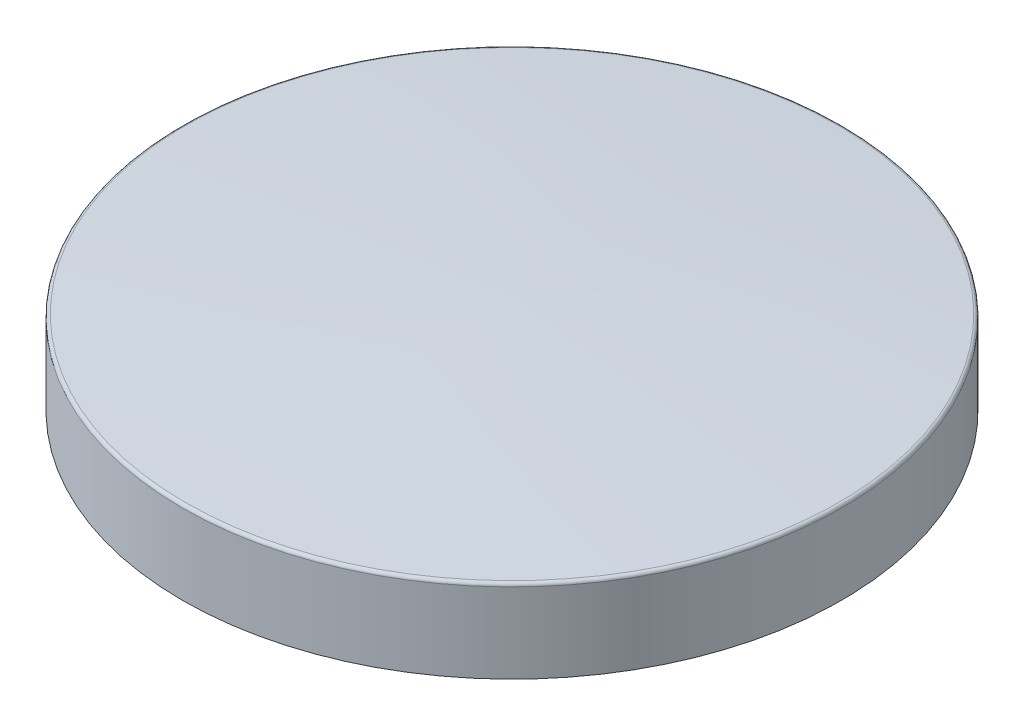
from build123d import *

# Parameters (mm, degrees)
FILLET1_R           = 0.1
CUT_EXTRUDE30_DEPTH = 2.5
CUT_EXTRUDE32_DEPTH = 2.5


with BuildPart() as part:
    # Sketch2 → Revolve1 (revolve)
    with BuildSketch(Plane.XY, mode=Mode.PRIVATE) as revolve1_sk:
        with BuildLine():
            Line((0, 0), (0, -2.994068148))
            Line((0, -2.994068148), (10, -2.994068148))
            Line((10, -2.994068148), (10, -0.476375913))
            ThreePointArc((10, -0.476375913), (5.003053336, -0.174092863), (0, 0))
        make_face()
    revolve(revolve1_sk.sketch.rotate(Axis((0, 0, 0), (0, -1, 0)), 90), axis=Axis((0, 0, 0), (0, -1, 0)))  # turned: the seam where the file's is

    # Fillet1
    fillet1_edges = [part.edges().sort_by_distance(p)[0] for p in [
        (0, -0.476375913, -10),
    ]]
    fillet(fillet1_edges, radius=FILLET1_R)

    # Sketch14 → Cut-Extrude30 (cut)
    with BuildSketch(Plane(origin=(0, -2.994068148, 0), x_dir=(-1, 0, 0), z_dir=(0, -1, 0))):
        Polygon((5.240635003, 5.742951642), (4.130859362, 5.742951642), (4.130859362, 1.742951642), (4.84880808, 1.742951642), (4.84880808, 5.076284975), (5.6693209, 5.076284975), align=None)
        with BuildLine():
            Line((0.438551669, 4.768592667), (1.156500387, 4.768592667))
            add(Edge.make_bspline(
                [(1.156500387, 4.768592667), (1.151431396, 4.804480362), (1.141493975, 4.874835812), (1.117715056, 4.976692975), (1.089272902, 5.073311466), (1.053764326, 5.164385313), (1.012118543, 5.250076748), (0.964759045, 5.330679823), (0.911173856, 5.405848574), (0.870100242, 5.451130528), (0.849609362, 5.473720872)],
                knots=[0, 0, 0, 0, 1.111473889, 2.178970933, 3.205615836, 4.199322666, 5.174200091, 6.12565194, 7.064921805, 8, 8, 8, 8], degree=3))
            add(Edge.make_bspline(
                [(0.849609362, 5.473720872), (0.820053982, 5.503527195), (0.761803436, 5.562272323), (0.664459941, 5.637518344), (0.562425981, 5.702638658), (0.453655221, 5.754266514), (0.339840215, 5.796053283), (0.220075866, 5.824121549), (0.094851577, 5.842745092), (0.009401752, 5.844579576), (-0.034204741, 5.845515744)],
                knots=[0, 0, 0, 0, 1.01925491, 2.00884431, 2.983262333, 3.955970413, 4.92937149, 5.924503185, 6.940838805, 8, 8, 8, 8], degree=3))
            add(Edge.make_bspline(
                [(-0.034204741, 5.845515744), (-0.072973157, 5.844600498), (-0.149184051, 5.842801308), (-0.26119489, 5.828358388), (-0.367987851, 5.803027115), (-0.470691766, 5.769907043), (-0.567796197, 5.724841651), (-0.661444331, 5.672530322), (-0.749019638, 5.608368303), (-0.830727026, 5.535871679), (-0.905790845, 5.457459484), (-0.970796441, 5.373643295), (-1.026682919, 5.286662037), (-1.072725984, 5.195793059), (-1.108126845, 5.100882602), (-1.132696092, 5.002478949), (-1.148777261, 4.900799235), (-1.150379365, 4.831688903), (-1.15119192, 4.796637539)],
                knots=[0, 0, 0, 0, 1.091422571, 2.145516843, 3.172569842, 4.178562979, 5.178154469, 6.181868002, 7.194278174, 8.227918432, 9.254613415, 10.245994977, 11.209837596, 12.161663635, 13.10878368, 14.055455738, 15.013766427, 16, 16, 16, 16], degree=3))
            add(Edge.make_bspline(
                [(-1.15119192, 4.796637539), (-1.149524509, 4.753229343), (-1.146241888, 4.667771951), (-1.119305607, 4.542698708), (-1.077143004, 4.423106368), (-1.016235022, 4.310668207), (-0.940084532, 4.205690219), (-0.846650431, 4.111682132), (-0.738593964, 4.027170029), (-0.657474536, 3.981753214), (-0.61593551, 3.958496513)],
                knots=[0, 0, 0, 0, 0.992805628, 1.954529043, 2.915727527, 3.886831945, 4.871318353, 5.87440735, 6.911542536, 8, 8, 8, 8], degree=3))
            add(Edge.make_bspline(
                [(-0.61593551, 3.958496513), (-0.64444726, 3.949135506), (-0.70047157, 3.930741545), (-0.78010339, 3.894514848), (-0.855824152, 3.854925073), (-0.926329971, 3.80893219), (-0.992322112, 3.758395948), (-1.053398281, 3.702884346), (-1.109923392, 3.642518423), (-1.160974697, 3.576966191), (-1.206284724, 3.507276029), (-1.246938999, 3.43505774), (-1.280399733, 3.359216119), (-1.308745141, 3.28061733), (-1.330325721, 3.198554967), (-1.345520377, 3.113347016), (-1.354303262, 3.025187842), (-1.355642802, 2.965460054), (-1.356320125, 2.935259334)],
                knots=[0, 0, 0, 0, 1.059543567, 2.081955587, 3.086750234, 4.076226789, 5.052108497, 6.020845489, 6.989030705, 7.970690546, 8.952259656, 9.923888338, 10.895517021, 11.877585046, 12.873342345, 13.889638361, 14.932918083, 16, 16, 16, 16], degree=3))
            add(Edge.make_bspline(
                [(-1.356320125, 2.935259334), (-1.354947099, 2.890876537), (-1.35223977, 2.8033627), (-1.335027839, 2.674463774), (-1.302982324, 2.551570101), (-1.260824675, 2.433267602), (-1.204590946, 2.321083521), (-1.138413301, 2.212443385), (-1.057067679, 2.111114805), (-0.966665987, 2.014418915), (-0.866269638, 1.926507342), (-0.757423663, 1.850291964), (-0.642521492, 1.784885609), (-0.520836171, 1.731786866), (-0.392409975, 1.690894762), (-0.257529157, 1.661336064), (-0.115626984, 1.643251563), (-0.018767648, 1.641355746), (0.030699105, 1.640387539)],
                knots=[0, 0, 0, 0, 1.005138573, 1.981928558, 2.936866704, 3.876260664, 4.820238198, 5.773547, 6.751179199, 7.756627054, 8.768222608, 9.766606018, 10.760583154, 11.757261445, 12.767156078, 13.807575856, 14.880313354, 16, 16, 16, 16], degree=3))
            add(Edge.make_bspline(
                [(0.030699105, 1.640387539), (0.077493856, 1.64140835), (0.1689948, 1.64340441), (0.30283408, 1.660681326), (0.430035646, 1.688550393), (0.55092412, 1.727834154), (0.665031794, 1.778778478), (0.77339344, 1.839441738), (0.873846725, 1.913322849), (0.967510898, 1.997086678), (1.052308203, 2.091064938), (1.128097025, 2.193080669), (1.193206207, 2.303521795), (1.247902761, 2.421916467), (1.291759085, 2.548472382), (1.326352825, 2.682932185), (1.350517118, 2.825558568), (1.357876404, 2.923688553), (1.361628592, 2.973720872)],
                knots=[0, 0, 0, 0, 1.066544725, 2.085487077, 3.070979577, 4.031932826, 4.977951092, 5.916076795, 6.857635327, 7.814973522, 8.776389752, 9.738577119, 10.707772778, 11.69409279, 12.707140348, 13.757286496, 14.856535458, 16, 16, 16, 16], degree=3))
            Line((1.361628592, 2.973720872), (0.643679875, 2.973720872))
            add(Edge.make_bspline(
                [(0.643679875, 2.973720872), (0.639130308, 2.948563965), (0.630268835, 2.899564292), (0.612985075, 2.828623657), (0.590461925, 2.763141069), (0.564419559, 2.702534521), (0.536289883, 2.646008271), (0.502302508, 2.595649971), (0.464947849, 2.550092188), (0.411044805, 2.495932594), (0.333986691, 2.440285872), (0.229932708, 2.391926223), (0.114182505, 2.363581528), (0.03326157, 2.360123562), (-0.008563715, 2.358336257)],
                knots=[0, 0, 0, 0, 0.928156231, 1.807827665, 2.648129825, 3.438902246, 4.202261636, 4.936546065, 5.639352463, 6.338805438, 7.70633318, 9.064371875, 10.482673459, 12, 12, 12, 12], degree=3))
            add(Edge.make_bspline(
                [(-0.008563715, 2.358336257), (-0.03075769, 2.358716847), (-0.074230721, 2.359462337), (-0.13808613, 2.367725099), (-0.198917399, 2.381333873), (-0.256837828, 2.399827693), (-0.312216142, 2.423010853), (-0.363994283, 2.45290415), (-0.41322762, 2.487659375), (-0.459380941, 2.526733475), (-0.50202756, 2.569310256), (-0.537512055, 2.616456807), (-0.569942317, 2.664366131), (-0.593927971, 2.716172622), (-0.614944572, 2.769088539), (-0.627807806, 2.825034563), (-0.637520471, 2.882837098), (-0.638084932, 2.922394615), (-0.638371408, 2.942470872)],
                knots=[0, 0, 0, 0, 1.110435564, 2.175094844, 3.216326037, 4.226890168, 5.215276772, 6.21526065, 7.213097102, 8.228249917, 9.239874822, 10.221364777, 11.178138315, 12.128914389, 13.072518965, 14.022636769, 14.996447288, 16, 16, 16, 16], degree=3))
            add(Edge.make_bspline(
                [(-0.638371408, 2.942470872), (-0.637610868, 2.964427681), (-0.636096809, 3.008138655), (-0.623726784, 3.07192563), (-0.604191901, 3.133283559), (-0.577055562, 3.191940721), (-0.540818005, 3.247680916), (-0.498058092, 3.301622462), (-0.44540705, 3.350957797), (-0.387641805, 3.399724281), (-0.320656814, 3.442233947), (-0.24771434, 3.481464123), (-0.166897342, 3.512679231), (-0.080178634, 3.540560104), (0.014082149, 3.560923861), (0.115299682, 3.575709934), (0.223310686, 3.586715873), (0.297764075, 3.588294856), (0.335987567, 3.589105488)],
                knots=[0, 0, 0, 0, 0.809814727, 1.612155564, 2.388397, 3.182215007, 3.988903953, 4.837162975, 5.715530372, 6.646997145, 7.623086902, 8.637258368, 9.698941581, 10.815059213, 11.996518529, 13.252603015, 14.589518788, 16, 16, 16, 16], degree=3))
            Line((0.335987567, 3.589105488), (0.335987567, 4.255772154))
            add(Edge.make_bspline(
                [(0.335987567, 4.255772154), (0.288397046, 4.259825115), (0.199364607, 4.267407403), (0.075782807, 4.285138846), (-0.028257138, 4.308839838), (-0.11525583, 4.337433803), (-0.18749397, 4.374155903), (-0.25060081, 4.41469548), (-0.304951406, 4.461776274), (-0.35088495, 4.513994342), (-0.387630356, 4.570071651), (-0.413636614, 4.629136592), (-0.430809788, 4.689361624), (-0.432436944, 4.730553731), (-0.433243202, 4.750964462)],
                knots=[0, 0, 0, 0, 1.70044513, 3.18119609, 4.440695891, 5.496282586, 6.431922213, 7.318171381, 8.16090191, 8.983045123, 9.787564368, 10.536848927, 11.275007137, 12, 12, 12, 12], degree=3))
            add(Edge.make_bspline(
                [(-0.433243202, 4.750964462), (-0.431852177, 4.777006339), (-0.429137189, 4.82783457), (-0.408051124, 4.900580475), (-0.371448103, 4.96542742), (-0.32236988, 5.022238949), (-0.262566359, 5.069692196), (-0.192466148, 5.104142444), (-0.113590427, 5.124383503), (-0.058097107, 5.126481818), (-0.029397049, 5.127567026)],
                knots=[0, 0, 0, 0, 1.009664648, 1.970651636, 2.907870547, 3.878035693, 4.867062054, 5.849714035, 6.887914197, 8, 8, 8, 8], degree=3))
            add(Edge.make_bspline(
                [(-0.029397049, 5.127567026), (-0.003383672, 5.126286595), (0.048234834, 5.123745828), (0.12371654, 5.104782212), (0.195399012, 5.072859324), (0.26179791, 5.028839543), (0.321954752, 4.975973653), (0.371326162, 4.913364979), (0.412390961, 4.844764516), (0.429797248, 4.794082822), (0.438551669, 4.768592667)],
                knots=[0, 0, 0, 0, 0.98818071, 1.960853194, 2.938124878, 3.957524365, 4.978590984, 5.968022688, 6.978025184, 8, 8, 8, 8], degree=3))
        make_face()
        with BuildLine():
            Line((-3.996544484, 5.742951642), (-5.817858587, 5.742951642))
            Line((-5.817858587, 5.742951642), (-5.817858587, 5.076284975))
            Line((-5.817858587, 5.076284975), (-4.565454741, 5.076284975))
            Line((-4.565454741, 5.076284975), (-4.409204741, 4.319874719))
            add(Edge.make_bspline(
                [(-4.409204741, 4.319874719), (-4.43049604, 4.325804614), (-4.472486857, 4.337499587), (-4.535746074, 4.349228164), (-4.597053071, 4.356830256), (-4.637282348, 4.357844273), (-4.656800895, 4.358336257)],
                knots=[0, 0, 0, 0, 1.05461699, 2.079921384, 3.068411212, 4, 4, 4, 4], degree=3))
            add(Edge.make_bspline(
                [(-4.656800895, 4.358336257), (-4.699333852, 4.357361639), (-4.783175681, 4.355440452), (-4.905825638, 4.337202122), (-5.023270217, 4.308477304), (-5.135150024, 4.267509787), (-5.241355769, 4.214189506), (-5.342016194, 4.149686913), (-5.437254842, 4.073888718), (-5.525379875, 3.986747464), (-5.606352836, 3.891064395), (-5.676754207, 3.787573031), (-5.736881371, 3.677749058), (-5.784704439, 3.560909814), (-5.822450481, 3.437789127), (-5.849726614, 3.308308098), (-5.865856354, 3.172313273), (-5.86803135, 3.079533726), (-5.869140638, 3.032214462)],
                knots=[0, 0, 0, 0, 1.01440847, 1.999622559, 2.951875003, 3.895578053, 4.836219714, 5.782137149, 6.743708247, 7.735272588, 8.734977101, 9.730283169, 10.717124674, 11.717316708, 12.737475749, 13.78628267, 14.87096371, 16, 16, 16, 16], degree=3))
            add(Edge.make_bspline(
                [(-5.869140638, 3.032214462), (-5.867785071, 2.984358015), (-5.865110139, 2.889923255), (-5.847658663, 2.751070755), (-5.816856493, 2.618081406), (-5.774546632, 2.490599199), (-5.718806098, 2.369561098), (-5.651770477, 2.253713238), (-5.572306378, 2.143915521), (-5.481193615, 2.041293508), (-5.38214209, 1.947495017), (-5.276675598, 1.864980305), (-5.165535073, 1.795544844), (-5.048717832, 1.739429252), (-4.926894094, 1.695031594), (-4.800026884, 1.662712219), (-4.667499644, 1.644178853), (-4.577530867, 1.641665198), (-4.531800895, 1.640387539)],
                knots=[0, 0, 0, 0, 1.06808661, 2.107647099, 3.116961351, 4.110378221, 5.100014249, 6.085620622, 7.093190682, 8.119403071, 9.144090782, 10.133780668, 11.103064255, 12.062861538, 13.020824475, 13.992378307, 14.979551724, 16, 16, 16, 16], degree=3))
            add(Edge.make_bspline(
                [(-4.531800895, 1.640387539), (-4.490905942, 1.641432743), (-4.410252537, 1.643494105), (-4.291453613, 1.656164319), (-4.176918258, 1.678565377), (-4.067254529, 1.710985507), (-3.961308581, 1.750887287), (-3.860305179, 1.800792003), (-3.763689292, 1.859749402), (-3.671735273, 1.926683511), (-3.585937243, 2.002082188), (-3.507629893, 2.084619032), (-3.436339141, 2.173253705), (-3.373590495, 2.269079689), (-3.319580654, 2.371955408), (-3.271683626, 2.480668447), (-3.232479429, 2.596354117), (-3.212584428, 2.676553851), (-3.202473972, 2.717310616)],
                knots=[0, 0, 0, 0, 1.054957082, 2.080596141, 3.077793124, 4.061112343, 5.027190972, 5.994718051, 6.962465889, 7.943658696, 8.924948258, 9.904494768, 10.875059, 11.855380583, 12.854004648, 13.869083016, 14.917087635, 16, 16, 16, 16], degree=3))
            Line((-3.202473972, 2.717310616), (-4.022986792, 2.717310616))
            add(Edge.make_bspline(
                [(-4.022986792, 2.717310616), (-4.037985786, 2.689067837), (-4.06713462, 2.63418122), (-4.122582145, 2.561310988), (-4.18465213, 2.499170385), (-4.252784668, 2.447152284), (-4.327421218, 2.408181208), (-4.405520479, 2.378627346), (-4.48806358, 2.361549264), (-4.544279077, 2.359414335), (-4.572666279, 2.358336257)],
                knots=[0, 0, 0, 0, 1.104910296, 2.147267069, 3.153527244, 4.136738762, 5.099945312, 6.05603338, 7.018353, 8, 8, 8, 8], degree=3))
            add(Edge.make_bspline(
                [(-4.572666279, 2.358336257), (-4.592451778, 2.359080679), (-4.631380081, 2.360545342), (-4.68873478, 2.368293777), (-4.74348236, 2.382969137), (-4.796029855, 2.403291099), (-4.846518423, 2.428634882), (-4.894224292, 2.460629756), (-4.939977458, 2.497457042), (-4.983081373, 2.539716477), (-5.022121095, 2.586825918), (-5.056354661, 2.637448223), (-5.08696419, 2.690458555), (-5.109637137, 2.747956785), (-5.128204362, 2.808225997), (-5.141878018, 2.871720818), (-5.15004957, 2.938515407), (-5.150806037, 2.9841142), (-5.15119192, 3.007374719)],
                knots=[0, 0, 0, 0, 0.978869489, 1.925942215, 2.855067702, 3.774946051, 4.70828698, 5.642468714, 6.60995405, 7.609372294, 8.622401667, 9.629904756, 10.629323, 11.642352373, 12.678539694, 13.745912462, 14.850161547, 16, 16, 16, 16], degree=3))
            add(Edge.make_bspline(
                [(-5.15119192, 3.007374719), (-5.150744058, 3.030095308), (-5.149872283, 3.074321487), (-5.142660787, 3.139261359), (-5.12975956, 3.200877545), (-5.112181528, 3.25964198), (-5.089679548, 3.315197816), (-5.062180624, 3.367875749), (-5.029567278, 3.417409511), (-4.991664416, 3.462790644), (-4.951245194, 3.504415509), (-4.907821962, 3.540820285), (-4.861785939, 3.571033721), (-4.81456764, 3.59741093), (-4.764282278, 3.616607688), (-4.71206057, 3.629827787), (-4.657957434, 3.639528163), (-4.62105486, 3.640098096), (-4.602313715, 3.640387539)],
                knots=[0, 0, 0, 0, 1.166249705, 2.270133367, 3.348514167, 4.393962215, 5.415026464, 6.420877785, 7.440098956, 8.453121383, 9.451844239, 10.415694839, 11.355045125, 12.27538808, 13.187007209, 14.108269027, 15.039275622, 16, 16, 16, 16], degree=3))
            add(Edge.make_bspline(
                [(-4.602313715, 3.640387539), (-4.581956477, 3.639615095), (-4.541156203, 3.638066951), (-4.480537209, 3.625470119), (-4.420649111, 3.60508372), (-4.361158871, 3.576957451), (-4.302657031, 3.540149041), (-4.2435997, 3.496976995), (-4.185963653, 3.444304455), (-4.149317051, 3.405073828), (-4.130358587, 3.384778565)],
                knots=[0, 0, 0, 0, 0.88288272, 1.769486374, 2.674910571, 3.623812639, 4.617874466, 5.670434592, 6.794841017, 8, 8, 8, 8], degree=3))
            Line((-4.130358587, 3.384778565), (-3.52619192, 3.52340036))
            Line((-3.52619192, 3.52340036), (-3.996544484, 5.742951642))
        make_face()
        with BuildLine():
            Line((5.207782439, -3.103202205), (5.925731157, -3.103202205))
            add(Edge.make_bspline(
                [(5.925731157, -3.103202205), (5.922630446, -3.048893182), (5.916571844, -2.942776613), (5.892472257, -2.788638899), (5.860179637, -2.642995709), (5.817080849, -2.506356519), (5.762924401, -2.378770979), (5.69910388, -2.259804142), (5.623988815, -2.150082372), (5.539177901, -2.05013481), (5.446110996, -1.96047093), (5.346720259, -1.8809693), (5.239485376, -1.815366556), (5.126365614, -1.761381572), (5.007380237, -1.718250078), (4.881403455, -1.689413184), (4.749526044, -1.669884557), (4.659245277, -1.668175723), (4.613231157, -1.667304769)],
                knots=[0, 0, 0, 0, 1.199038563, 2.342849363, 3.436047546, 4.486744587, 5.497670872, 6.488682221, 7.459191391, 8.424610317, 9.374430501, 10.305433194, 11.225809216, 12.140057399, 13.06607119, 14.010487599, 14.985989317, 16, 16, 16, 16], degree=3))
            add(Edge.make_bspline(
                [(4.613231157, -1.667304769), (4.556749477, -1.669067146), (4.446484002, -1.672507719), (4.286259522, -1.701856953), (4.136627375, -1.750948082), (3.997696331, -1.819541335), (3.870649134, -1.906681874), (3.755506852, -2.010582704), (3.655751571, -2.13342372), (3.570750813, -2.270093708), (3.500125343, -2.414807991), (3.450633955, -2.56444856), (3.418103798, -2.715044562), (3.414634256, -2.816448288), (3.412910644, -2.866823999)],
                knots=[0, 0, 0, 0, 1.075374347, 2.099382735, 3.09057751, 4.06680945, 5.040638231, 6.016817125, 7.011024321, 8.044445721, 9.0776792, 10.070479129, 11.0414456, 12, 12, 12, 12], degree=3))
            add(Edge.make_bspline(
                [(3.412910644, -2.866823999), (3.413581727, -2.89729479), (3.414932453, -2.958624965), (3.424324225, -3.051432573), (3.438413739, -3.145967972), (3.459657293, -3.242150107), (3.486149746, -3.34000594), (3.518288921, -3.439828318), (3.556820318, -3.541051287), (3.601100925, -3.644814093), (3.653927802, -3.751453613), (3.715437357, -3.862568415), (3.787262193, -3.978059932), (3.868534757, -4.098580267), (3.95964977, -4.22393934), (4.061052026, -4.35375953), (4.171573609, -4.488498283), (4.250013885, -4.578563578), (4.29031449, -4.62483682)],
                knots=[0, 0, 0, 0, 0.728284026, 1.46585585, 2.227944881, 3.01186502, 3.81876927, 4.650621989, 5.517437689, 6.406905708, 7.346299482, 8.360816762, 9.441613733, 10.596154504, 11.834900912, 13.145207542, 14.533280747, 16, 16, 16, 16], degree=3))
            Line((4.29031449, -4.62483682), (4.707782439, -5.103202205))
            Line((4.707782439, -5.103202205), (3.361628592, -5.103202205))
            Line((3.361628592, -5.103202205), (3.361628592, -5.769868871))
            Line((3.361628592, -5.769868871), (6.028295259, -5.769868871))
            Line((6.028295259, -5.769868871), (6.028295259, -5.40608682))
            Line((6.028295259, -5.40608682), (4.844000387, -4.145670153))
            add(Edge.make_bspline(
                [(4.844000387, -4.145670153), (4.809712007, -4.108903408), (4.743305584, -4.037697125), (4.648816087, -3.933123123), (4.563311439, -3.833884892), (4.488564648, -3.738925743), (4.420653099, -3.651325767), (4.362604963, -3.568444589), (4.313889145, -3.491031486), (4.261001214, -3.397684804), (4.210775066, -3.286352275), (4.164689535, -3.158092636), (4.136597214, -3.035505961), (4.132719586, -2.955625848), (4.130859362, -2.917304769)],
                knots=[0, 0, 0, 0, 1.246127091, 2.413378631, 3.493388633, 4.492180848, 5.408488754, 6.240484944, 6.999099869, 7.674939598, 8.898438119, 10.020720584, 11.050475521, 12, 12, 12, 12], degree=3))
            add(Edge.make_bspline(
                [(4.130859362, -2.917304769), (4.132250206, -2.880232081), (4.134945191, -2.808397806), (4.164560886, -2.706213931), (4.210442548, -2.613696864), (4.27509629, -2.533611118), (4.353412221, -2.467799351), (4.443913635, -2.418850407), (4.545862681, -2.39060709), (4.617330904, -2.387072036), (4.654096541, -2.385253487)],
                knots=[0, 0, 0, 0, 1.062038974, 2.057870785, 3.028805853, 4.01125022, 4.991535629, 5.949134679, 6.94496649, 8, 8, 8, 8], degree=3))
            add(Edge.make_bspline(
                [(4.654096541, -2.385253487), (4.673090138, -2.385925281), (4.710482083, -2.387247815), (4.765445319, -2.396051569), (4.817746788, -2.411567267), (4.867968632, -2.432356119), (4.915574872, -2.459911891), (4.96044543, -2.49387877), (5.003053073, -2.533393581), (5.043202386, -2.578332766), (5.079743503, -2.628484909), (5.112199188, -2.683391974), (5.139034637, -2.743019877), (5.162661542, -2.80658144), (5.180883742, -2.874759366), (5.194151763, -2.947145617), (5.204238554, -3.02362243), (5.206579654, -3.076193047), (5.207782439, -3.103202205)],
                knots=[0, 0, 0, 0, 0.903469896, 1.778625579, 2.63899355, 3.493148037, 4.358286772, 5.247621495, 6.164656832, 7.118446693, 8.109501108, 9.111810964, 10.146451449, 11.215617525, 12.33435995, 13.498009769, 14.714554818, 16, 16, 16, 16], degree=3))
        make_face()
        Polygon((-0.248948331, -1.667304769), (-0.997345766, -1.667304769), (-0.997345766, -4.282689384), (-1.356320125, -4.282689384), (-1.356320125, -4.949356051), (-0.997345766, -4.949356051), (-0.997345766, -5.769868871), (-0.279397049, -5.769868871), (-0.279397049, -4.949356051), (1.412910644, -4.949356051), (1.412910644, -4.22259323), align=None)
        Polygon((-0.279397049, -4.282689384), (-0.279397049, -2.921311179), (0.606019618, -4.282689384), align=None, mode=Mode.SUBTRACT)
        with BuildLine():
            Line((-3.561448331, -1.769868871), (-4.397986792, -1.769868871))
            add(Edge.make_bspline(
                [(-4.397986792, -1.769868871), (-4.45328173, -1.770065137), (-4.559629471, -1.77044261), (-4.712977104, -1.776398141), (-4.853847995, -1.784685751), (-4.982450714, -1.797332865), (-5.098730243, -1.814101408), (-5.202803122, -1.833868746), (-5.294666309, -1.856397866), (-5.375094542, -1.884470926), (-5.447677046, -1.916136913), (-5.51533403, -1.952521713), (-5.579558108, -1.993220168), (-5.639920012, -2.039303167), (-5.696944302, -2.089941687), (-5.750738555, -2.145186701), (-5.800542611, -2.205506663), (-5.84604808, -2.270520429), (-5.887522652, -2.33891342), (-5.924177475, -2.410779539), (-5.953985238, -2.486168766), (-5.980323592, -2.563991562), (-5.999294255, -2.645360421), (-6.012488073, -2.729483201), (-6.022148071, -2.816656025), (-6.022703475, -2.875877372), (-6.022986792, -2.90608682)],
                knots=[0, 0, 0, 0, 1.749336639, 3.364467119, 4.854658419, 6.213483162, 7.451590619, 8.570285859, 9.5643256, 10.440900261, 11.26203566, 12.067320669, 12.869050712, 13.665104639, 14.467235401, 15.27997916, 16.102287765, 16.939272006, 17.78853747, 18.631303466, 19.488103222, 20.351255419, 21.228522269, 22.127379805, 23.044756219, 24, 24, 24, 24], degree=3))
            add(Edge.make_bspline(
                [(-6.022986792, -2.90608682), (-6.022250835, -2.937618544), (-6.020807758, -2.999446508), (-6.01303456, -3.090266745), (-5.998827595, -3.177157194), (-5.97730908, -3.259863453), (-5.952576342, -3.339414895), (-5.919688145, -3.414343749), (-5.882570564, -3.485739744), (-5.838487098, -3.552592958), (-5.790107647, -3.616388335), (-5.733843363, -3.674681636), (-5.673339308, -3.730605906), (-5.605194328, -3.780658239), (-5.532412318, -3.828222992), (-5.453547174, -3.871329325), (-5.369113599, -3.911060832), (-5.309752614, -3.933217865), (-5.279397049, -3.944548358)],
                knots=[0, 0, 0, 0, 1.099860209, 2.156625411, 3.176576793, 4.16617041, 5.135385252, 6.078461593, 7.016046972, 7.938469504, 8.868247731, 9.803980173, 10.76021508, 11.73834243, 12.748633912, 13.790971185, 14.870363756, 16, 16, 16, 16], degree=3))
            Line((-5.279397049, -3.944548358), (-6.202473972, -5.769868871))
            Line((-6.202473972, -5.769868871), (-5.404397049, -5.769868871))
            Line((-5.404397049, -5.769868871), (-4.522986792, -4.026279128))
            Line((-4.522986792, -4.026279128), (-4.279397049, -4.026279128))
            Line((-4.279397049, -4.026279128), (-4.279397049, -5.769868871))
            Line((-4.279397049, -5.769868871), (-3.561448331, -5.769868871))
            Line((-3.561448331, -5.769868871), (-3.561448331, -1.769868871))
        make_face()
        with BuildLine():
            Line((-4.279397049, -3.30833041), (-4.559044484, -3.30833041))
            add(Edge.make_bspline(
                [(-4.559044484, -3.30833041), (-4.593233708, -3.307945348), (-4.658698725, -3.307208037), (-4.752846017, -3.303788083), (-4.838354212, -3.295547683), (-4.91559051, -3.285136246), (-4.984943556, -3.273114739), (-5.045794747, -3.255887189), (-5.099081707, -3.237427433), (-5.144172982, -3.214486745), (-5.182697932, -3.188398207), (-5.21596176, -3.158760979), (-5.243475715, -3.124459662), (-5.266121104, -3.086426417), (-5.283736754, -3.04432485), (-5.29659483, -2.99861714), (-5.303780592, -2.948782618), (-5.304607339, -2.914390012), (-5.305038074, -2.896471435)],
                knots=[0, 0, 0, 0, 1.688639943, 3.233382647, 4.650958383, 5.928841754, 7.082724185, 8.122798841, 9.049171256, 9.863274652, 10.613301712, 11.341792392, 12.054588806, 12.776240173, 13.521029143, 14.301969904, 15.115324896, 16, 16, 16, 16], degree=3))
            add(Edge.make_bspline(
                [(-5.305038074, -2.896471435), (-5.304223729, -2.875272451), (-5.302624099, -2.833630975), (-5.286750799, -2.773681851), (-5.261483934, -2.718194835), (-5.226849983, -2.667420631), (-5.183233024, -2.622908459), (-5.133179123, -2.583670625), (-5.075607995, -2.552644282), (-5.022301462, -2.532179636), (-4.973804978, -2.519935427), (-4.93003843, -2.510811151), (-4.879356505, -2.504344515), (-4.82172094, -2.497485496), (-4.75727865, -2.49303777), (-4.685678385, -2.489791816), (-4.607125782, -2.488463737), (-4.552367157, -2.488039173), (-4.523788074, -2.487817589)],
                knots=[0, 0, 0, 0, 1.020303359, 2.004196876, 2.966617323, 3.9489082, 4.950758222, 5.960522915, 7.003732012, 8.091992268, 8.70421221, 9.413913587, 10.24622431, 11.166358409, 12.212345909, 13.359657661, 14.621978493, 16, 16, 16, 16], degree=3))
            Line((-4.523788074, -2.487817589), (-4.279397049, -2.487817589))
            Line((-4.279397049, -2.487817589), (-4.279397049, -3.30833041))
        make_face(mode=Mode.SUBTRACT)
    extrude(amount=-CUT_EXTRUDE30_DEPTH, mode=Mode.SUBTRACT)

    # Sketch15 → Cut-Extrude32 (cut)
    with BuildSketch(Plane(origin=(0, -2.994068148, 0), x_dir=(-1, 0, 0), z_dir=(0, -1, 0))):
        Polygon((4.84880808, 1.01972759), (4.04880808, 1.01972759), (4.04880808, 0.293381337), (0.34880808, 0.293381337), (0.34880808, 1.01972759), (-0.45119192, 1.01972759), (-0.45119192, 0.293381337), (-4.15119192, 0.293381337), (-4.15119192, 1.01972759), (-4.95119192, 1.01972759), (-4.95119192, -1.01972759), (-4.15119192, -1.01972759), (-4.15119192, -0.293381337), (-0.45119192, -0.293381337), (-0.45119192, -1.01972759), (0.34880808, -1.01972759), (0.34880808, -0.293381337), (4.04880808, -0.293381337), (4.04880808, -1.01972759), (4.84880808, -1.01972759), align=None)
    extrude(amount=-CUT_EXTRUDE32_DEPTH, mode=Mode.SUBTRACT)


solid = part.part
